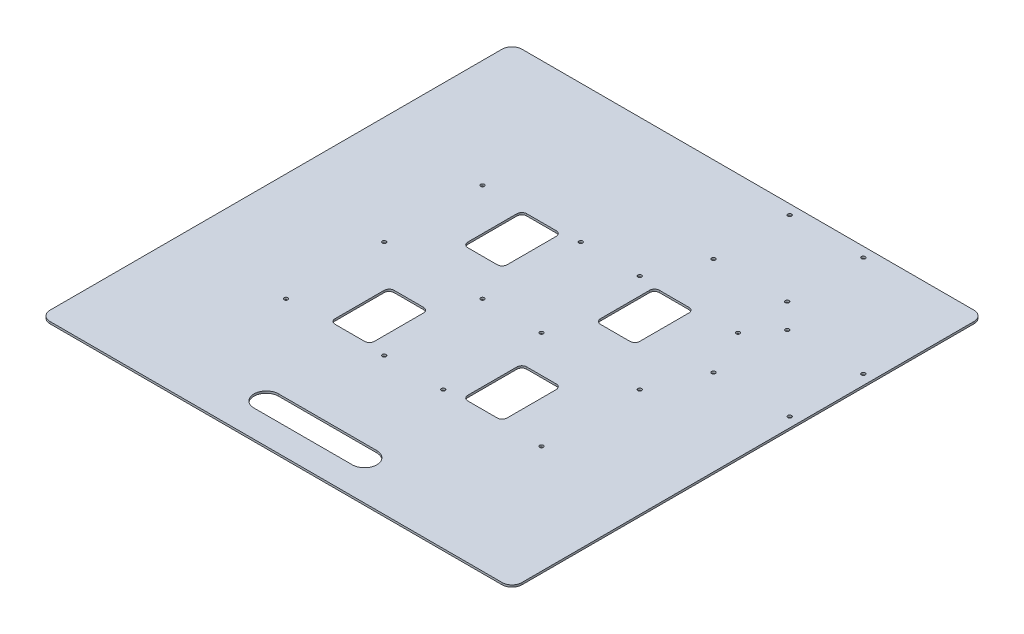
from build123d import *

# Parameters (mm, degrees)
SKETCH1_W                        = 609.6
SKETCH1_H                        = 609.6
BOSS_EXTRUDE1_DEPTH              = 2.65684
CUT_EXTRUDE1_DEPTH               = 3.65684
SKETCH3_R                        = 2.3876
CUT_EXTRUDE2_DEPTH               = 3.65684
LPATTERN1_COUNT                  = 2
LPATTERN1_PITCH                  = 203.2
CUT_EXTRUDE3_DEPTH               = 3.65684
FILLET1_R                        = 12.7
SKETCH5_R                        = 2.3876
CUT_EXTRUDE4_DEPTH               = 3.65684
F_10_0_1935_DIAMETER_HOLE1_D     = 4.9149
F_10_0_1935_DIAMETER_HOLE1_DEPTH = 2.65684


with BuildPart() as part:
    # Sketch1 → Boss-Extrude1 (new body)
    with BuildSketch(Plane(origin=(0, 0, 0), x_dir=(1, 0, 0), z_dir=(0, 1, 0))):
        Rectangle(SKETCH1_W, SKETCH1_H)
    extrude(amount=BOSS_EXTRUDE1_DEPTH)

    # Sketch2 → Cut-Extrude1 (cut, through all)
    with BuildSketch(Plane(origin=(0, 2.65684, 0), x_dir=(1, 0, 0), z_dir=(0, 1, 0))):
        with BuildLine():
            Line((-104.775, 123.825), (-66.675, 123.825))
            ThreePointArc((-66.675, 123.825), (-62.184871939, 121.965128061), (-60.325, 117.475))
            Line((-60.325, 117.475), (-60.325, 53.975))
            ThreePointArc((-60.325, 53.975), (-62.184871939, 49.484871939), (-66.675, 47.625))
            Line((-66.675, 47.625), (-104.775, 47.625))
            ThreePointArc((-104.775, 47.625), (-109.265128061, 49.484871939), (-111.125, 53.975))
            Line((-111.125, 53.975), (-111.125, 117.475))
            ThreePointArc((-111.125, 117.475), (-109.265128061, 121.965128061), (-104.775, 123.825))
        make_face()
        with BuildLine():
            Line((-104.775, -47.625), (-66.675, -47.625))
            ThreePointArc((-66.675, -47.625), (-62.184871939, -49.484871939), (-60.325, -53.975))
            Line((-60.325, -53.975), (-60.325, -117.475))
            ThreePointArc((-60.325, -117.475), (-62.184871939, -121.965128061), (-66.675, -123.825))
            Line((-66.675, -123.825), (-104.775, -123.825))
            ThreePointArc((-104.775, -123.825), (-109.265128061, -121.965128061), (-111.125, -117.475))
            Line((-111.125, -117.475), (-111.125, -53.975))
            ThreePointArc((-111.125, -53.975), (-109.265128061, -49.484871939), (-104.775, -47.625))
        make_face()
        with BuildLine():
            Line((66.675, -47.625), (104.775, -47.625))
            ThreePointArc((104.775, -47.625), (109.265128061, -49.484871939), (111.125, -53.975))
            Line((111.125, -53.975), (111.125, -117.475))
            ThreePointArc((111.125, -117.475), (109.265128061, -121.965128061), (104.775, -123.825))
            Line((104.775, -123.825), (66.675, -123.825))
            ThreePointArc((66.675, -123.825), (62.184871939, -121.965128061), (60.325, -117.475))
            Line((60.325, -117.475), (60.325, -53.975))
            ThreePointArc((60.325, -53.975), (62.184871939, -49.484871939), (66.675, -47.625))
        make_face()
        with BuildLine():
            Line((104.775, 123.825), (66.675, 123.825))
            ThreePointArc((66.675, 123.825), (62.184871939, 121.965128061), (60.325, 117.475))
            Line((60.325, 117.475), (60.325, 53.975))
            ThreePointArc((60.325, 53.975), (62.184871939, 49.484871939), (66.675, 47.625))
            Line((66.675, 47.625), (104.775, 47.625))
            ThreePointArc((104.775, 47.625), (109.265128061, 49.484871939), (111.125, 53.975))
            Line((111.125, 53.975), (111.125, 117.475))
            ThreePointArc((111.125, 117.475), (109.265128061, 121.965128061), (104.775, 123.825))
        make_face()
    extrude(amount=-CUT_EXTRUDE1_DEPTH, mode=Mode.SUBTRACT)

    # Sketch3 → Cut-Extrude2 (cut, through all)
    with BuildSketch(Plane(origin=(0, 2.65684, 0), x_dir=(1, 0, 0), z_dir=(0, 1, 0))):
        with Locations((-165.1, 127)):
            Circle(SKETCH3_R)
        with Locations((-165.1, 0)):
            Circle(SKETCH3_R)
        with Locations((-165.1, -127)):
            Circle(SKETCH3_R)
        with Locations((-38.1, 127)):
            Circle(SKETCH3_R)
        with Locations((-38.1, 0)):
            Circle(SKETCH3_R)
        with Locations((-38.1, -127)):
            Circle(SKETCH3_R)
    cut_extrude2 = extrude(amount=-CUT_EXTRUDE2_DEPTH, mode=Mode.SUBTRACT)

    # LPattern1: Cut-Extrude2 ×2
    with Locations(*[(i * LPATTERN1_PITCH, 0, 0) for i in range(1, LPATTERN1_COUNT)]):
        add(cut_extrude2, mode=Mode.SUBTRACT)

    # Sketch4 → Cut-Extrude3 (cut, through all)
    with BuildSketch(Plane(origin=(0, 2.65684, 0), x_dir=(1, 0, 0), z_dir=(0, 1, 0))):
        with BuildLine():
            Line((-63.5, -238.125), (63.5, -238.125))
            ThreePointArc((63.5, -238.125), (79.375, -254), (63.5, -269.875))
            Line((63.5, -269.875), (-63.5, -269.875))
            ThreePointArc((-63.5, -269.875), (-79.375, -254), (-63.5, -238.125))
        make_face()
    extrude(amount=-CUT_EXTRUDE3_DEPTH, mode=Mode.SUBTRACT)

    # Fillet1
    fillet1_edges = [part.edges().sort_by_distance(p)[0] for p in [
        (-304.8, 1.32842, 304.8),
        (304.8, 1.32842, 304.8),
        (-304.8, 1.32842, -304.8),
        (304.8, 1.32842, -304.8),
    ]]
    fillet(fillet1_edges, radius=FILLET1_R)

    # Sketch5 → Cut-Extrude4 (cut, through all)
    with BuildSketch(Plane(origin=(0, 2.65684, 0), x_dir=(1, 0, 0), z_dir=(0, 1, 0))):
        with Locations((161.925, 292.1)):
            Circle(SKETCH5_R)
        with Locations((66.675, 292.1)):
            Circle(SKETCH5_R)
        with Locations((161.925, 193.675)):
            Circle(SKETCH5_R)
        with Locations((66.675, 193.675)):
            Circle(SKETCH5_R)
        with Locations((193.675, 161.925)):
            Circle(SKETCH5_R)
        with Locations((193.675, 66.675)):
            Circle(SKETCH5_R)
        with Locations((292.1, 66.675)):
            Circle(SKETCH5_R)
        with Locations((292.1, 161.925)):
            Circle(SKETCH5_R)
    extrude(amount=-CUT_EXTRUDE4_DEPTH, mode=Mode.SUBTRACT)

    # #10 (0.1935) Diameter Hole1
    with Locations(Plane(origin=(0, 2.65684, 0), x_dir=(1, 0, 0), z_dir=(0, 1, 0))):
        with Locations((161.925, 292.1), (66.675, 292.1), (292.1, 161.925), (193.675, 161.925), (161.925, 193.675), (66.675, 193.675), (165.1, 127), (38.1, 127), (-38.1, 127), (292.1, 66.675), (193.675, 66.675), (165.1, 0), (165.1, -127), (-38.1, 0), (38.1, 0), (38.1, -127), (-38.1, -127), (-165.1, -127), (-165.1, 0), (-165.1, 127)):
            Hole(F_10_0_1935_DIAMETER_HOLE1_D / 2, depth=F_10_0_1935_DIAMETER_HOLE1_DEPTH)


solid = part.part
